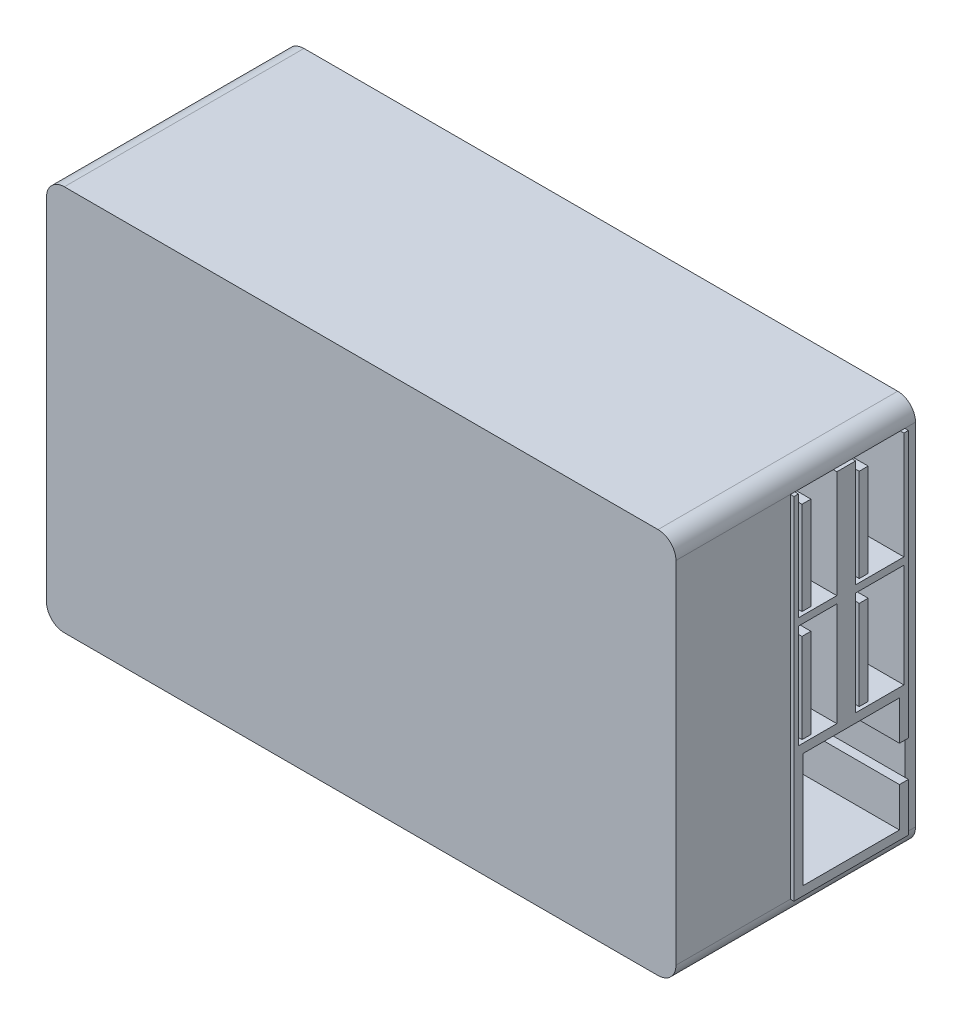
from build123d import *

# Parameters (mm, degrees)
ESQUISSE1_W             = 88
ESQUISSE1_H             = 54
ESQUISSE1_R             = 1.25
BOSS_EXTRU_1_DEPTH      = 33.5
ESQUISSE1_3_R           = 1.25
ENL_V_MAT_EXTRU_1_DEPTH = 10
CONG_1_R                = 2.5
ENL_V_MAT_EXTRU_2_DEPTH = 17.5
ESQUISSE2_7_W           = 2
ESQUISSE2_7_H           = 14.5
ESQUISSE2_7_W_2         = 0.625
ESQUISSE2_7_W_3         = 5.375
ESQUISSE2_7_H_2         = 0.5
ESQUISSE2_7_W_4         = 6.75
ESQUISSE2_7_H_3         = 15
BOSS_EXTRU_3_DEPTH      = 0.5
ESQUISSE2_8_W           = 1.25
ESQUISSE2_8_H           = 12.5
ESQUISSE2_8_H_2         = 13
BOSS_EXTRU_4_DEPTH      = 1
ESQUISSE3_W             = 9
ESQUISSE3_H             = 3.25
ENL_V_MAT_EXTRU_3_DEPTH = 10
ESQUISSE3_2_W           = 10
ESQUISSE3_2_H           = 4.25
ESQUISSE3_2_W_2         = 9
ESQUISSE3_2_H_2         = 3.25
BOSS_EXTRU_5_DEPTH      = 0.5
CONG_2_R                = 1.5
CONG_3_R                = 1
CONG_4_R                = 1


with BuildPart() as part:
    # Esquisse1 → Boss.-Extru.1 (new body)
    with BuildSketch(Plane.XY):
        Rectangle(ESQUISSE1_W, ESQUISSE1_H)
        with Locations((16.5, 24.5)):
            Circle(ESQUISSE1_R, mode=Mode.SUBTRACT)
        with Locations((16.5, -24.5)):
            Circle(ESQUISSE1_R, mode=Mode.SUBTRACT)
        with Locations((-41.5, -24.5)):
            Circle(ESQUISSE1_R, mode=Mode.SUBTRACT)
        with Locations((-41.5, 24.5)):
            Circle(ESQUISSE1_R, mode=Mode.SUBTRACT)
        with Locations((16.5, -24.5)):
            Circle(ESQUISSE1_R)
        with Locations((16.5, 24.5)):
            Circle(ESQUISSE1_R)
        with Locations((-41.5, 24.5)):
            Circle(ESQUISSE1_R)
        with Locations((-41.5, -24.5)):
            Circle(ESQUISSE1_R)
    extrude(amount=BOSS_EXTRU_1_DEPTH)

    # Esquisse1_3 → Enl_v. mat.-Extru.1 (cut)
    with BuildSketch(Plane.XY):
        with Locations((16.5, 24.5)):
            Circle(ESQUISSE1_3_R)
        with Locations((-41.5, 24.5)):
            Circle(ESQUISSE1_3_R)
        with Locations((-41.5, -24.5)):
            Circle(ESQUISSE1_3_R)
        with Locations((16.5, -24.5)):
            Circle(ESQUISSE1_3_R)
    extrude(amount=ENL_V_MAT_EXTRU_1_DEPTH, mode=Mode.SUBTRACT)

    # Cong_1
    cong_1_edges = [part.edges().sort_by_distance(p)[0] for p in [
        (44, -27, 16.75),
        (-44, -27, 16.75),
        (-44, 27, 16.75),
        (44, 27, 16.75),
    ]]
    fillet(cong_1_edges, radius=CONG_1_R)

    # Esquisse2 → Enl_v. mat.-Extru.2 (cut)
    with BuildSketch(Plane(origin=(44, 0, 0), x_dir=(0, 0, -1), z_dir=(1, 0, 0))):
        Polygon((-2.75, -17.75), (-1.5, -17.75), (-1.5, -12.75), (-2.75, -12.75), (-2.75, -7.25), (-16.25, -7.25), (-16.25, -23.25), (-2.75, -23.25), align=None)
        Polygon((-16.875, -5), (-16.875, -6), (-11.5, -6), (-11.5, 8.5), (-16.875, 8.5), (-16.875, 7.5), (-15.625, 7.5), (-15.625, -5), align=None)
        Polygon((-8.875, -6), (-2.125, -6), (-2.125, 8.5), (-8.875, 8.5), (-8.875, 7.5), (-7.625, 7.5), (-7.625, -5), (-8.875, -5), align=None)
        Polygon((-16.875, 10.5), (-16.875, 9.5), (-11.5, 9.5), (-11.5, 24.5), (-16.875, 24.5), (-16.875, 23.5), (-15.625, 23.5), (-15.625, 10.5), align=None)
        Polygon((-8.875, 9.5), (-2.125, 9.5), (-2.125, 24.5), (-8.875, 24.5), (-8.875, 23.5), (-7.625, 23.5), (-7.625, 10.5), (-8.875, 10.5), align=None)
    extrude(amount=-ENL_V_MAT_EXTRU_2_DEPTH, mode=Mode.SUBTRACT)

    # Esquisse2_7 → Boss.-Extru.3 (add)
    with BuildSketch(Plane(origin=(44, 0, 0), x_dir=(0, 0, -1), z_dir=(1, 0, 0))):
        Polygon((-17.5, -24.5), (-1.5, -24.5), (-1.5, -17.75), (-2.75, -17.75), (-2.75, -23.25), (-16.25, -23.25), (-16.25, -7.25), (-2.75, -7.25), (-2.75, -12.75), (-1.5, -12.75), (-1.5, -6), (-2.125, -6), (-8.875, -6), (-9.5, -6), (-11.5, -6), (-16.875, -6), (-17.5, -6), align=None)
        with Locations((-10.5, 1.25)):
            Rectangle(ESQUISSE2_7_W, ESQUISSE2_7_H)
        Polygon((-9.5, 8.5), (-9.5, -6), (-8.875, -6), (-8.875, -5), (-8.875, 7.5), (-8.875, 8.5), align=None)
        with Locations((-1.8125, 1.25)):
            Rectangle(ESQUISSE2_7_W_2, ESQUISSE2_7_H)
        Polygon((-17.5, 8.5), (-17.5, -6), (-16.875, -6), (-16.875, -5), (-16.875, 7.5), (-16.875, 8.5), align=None)
        with Locations((-14.1875, 8.75)):
            Rectangle(ESQUISSE2_7_W_3, ESQUISSE2_7_H_2)
        with Locations((-17.1875, 8.75)):
            Rectangle(ESQUISSE2_7_W_2, ESQUISSE2_7_H_2)
        with Locations((-17.1875, 9.25)):
            Rectangle(ESQUISSE2_7_W_2, ESQUISSE2_7_H_2)
        with Locations((-14.1875, 9.25)):
            Rectangle(ESQUISSE2_7_W_3, ESQUISSE2_7_H_2)
        with Locations((-10.5, 9.25)):
            Rectangle(ESQUISSE2_7_W, ESQUISSE2_7_H_2)
        with Locations((-10.5, 8.75)):
            Rectangle(ESQUISSE2_7_W, ESQUISSE2_7_H_2)
        with Locations((-9.1875, 8.75)):
            Rectangle(ESQUISSE2_7_W_2, ESQUISSE2_7_H_2)
        with Locations((-9.1875, 9.25)):
            Rectangle(ESQUISSE2_7_W_2, ESQUISSE2_7_H_2)
        with Locations((-5.5, 8.75)):
            Rectangle(ESQUISSE2_7_W_4, ESQUISSE2_7_H_2)
        with Locations((-5.5, 9.25)):
            Rectangle(ESQUISSE2_7_W_4, ESQUISSE2_7_H_2)
        with Locations((-1.8125, 8.75)):
            Rectangle(ESQUISSE2_7_W_2, ESQUISSE2_7_H_2)
        with Locations((-1.8125, 9.25)):
            Rectangle(ESQUISSE2_7_W_2, ESQUISSE2_7_H_2)
        with Locations((-1.8125, 17)):
            Rectangle(ESQUISSE2_7_W_2, ESQUISSE2_7_H_3)
        Polygon((-9.5, 24.5), (-9.5, 9.5), (-8.875, 9.5), (-8.875, 10.5), (-8.875, 23.5), (-8.875, 24.5), align=None)
        with Locations((-10.5, 17)):
            Rectangle(ESQUISSE2_7_W, ESQUISSE2_7_H_3)
        Polygon((-17.5, 24.5), (-17.5, 9.5), (-16.875, 9.5), (-16.875, 10.5), (-16.875, 23.5), (-16.875, 24.5), align=None)
    extrude(amount=BOSS_EXTRU_3_DEPTH)

    # Esquisse2_8 → Boss.-Extru.4 (add)
    with BuildSketch(Plane(origin=(44, 0, 0), x_dir=(0, 0, -1), z_dir=(1, 0, 0))):
        with Locations((-16.25, 1.25)):
            Rectangle(ESQUISSE2_8_W, ESQUISSE2_8_H)
        with Locations((-8.25, 1.25)):
            Rectangle(ESQUISSE2_8_W, ESQUISSE2_8_H)
        with Locations((-8.25, 17)):
            Rectangle(ESQUISSE2_8_W, ESQUISSE2_8_H_2)
        Polygon((-16.875, 23.5), (-16.875, 10.5), (-15.625, 10.5), (-15.625, 23), (-15.625, 23.5), align=None)
    extrude(amount=BOSS_EXTRU_4_DEPTH)

    # Esquisse3 → Enl_v. mat.-Extru.3 (cut)
    with BuildSketch(Plane.XZ.offset(27)):
        with Locations((-32.75, 3.125)):
            Rectangle(ESQUISSE3_W, ESQUISSE3_H)
    extrude(amount=-ENL_V_MAT_EXTRU_3_DEPTH, mode=Mode.SUBTRACT)

    # Cong_4
    cong_4_edges = [part.edges().sort_by_distance(p)[0] for p in [
        (-28.25, -22, 4.75),
        (-32.75, -17, 1.5),
        (-28.25, -22, 1.5),
        (-37.25, -17, 3.125),
        (-37.25, -22, 1.5),
        (-37.25, -22, 4.75),
        (-28.25, -17, 3.125),
        (-32.75, -17, 4.75),
    ]]
    fillet(cong_4_edges, radius=CONG_4_R)


with BuildPart() as body_2:
    # Esquisse3_2 → Boss.-Extru.5 (new body)
    with BuildSketch(Plane.XZ.offset(27)):
        with Locations((-32.75, 3.125)):
            Rectangle(ESQUISSE3_2_W, ESQUISSE3_2_H)
        with Locations((-32.75, 3.125)):
            Rectangle(ESQUISSE3_2_W_2, ESQUISSE3_2_H_2, mode=Mode.SUBTRACT)
    extrude(amount=BOSS_EXTRU_5_DEPTH)

    # Cong_2
    cong_2_edges = [body_2.edges().sort_by_distance(p)[0] for p in [
        (-27.75, -27.25, 5.25),
        (-27.75, -27.25, 1),
        (-37.75, -27.25, 1),
        (-37.75, -27.25, 5.25),
    ]]
    fillet(cong_2_edges, radius=CONG_2_R)

    # Cong_3
    cong_3_edges = [body_2.edges().sort_by_distance(p)[0] for p in [
        (-37.25, -27.25, 4.75),
        (-37.25, -27.25, 1.5),
        (-28.25, -27.25, 1.5),
        (-28.25, -27.25, 4.75),
    ]]
    fillet(cong_3_edges, radius=CONG_3_R)


solid = Compound([part.part, body_2.part])
